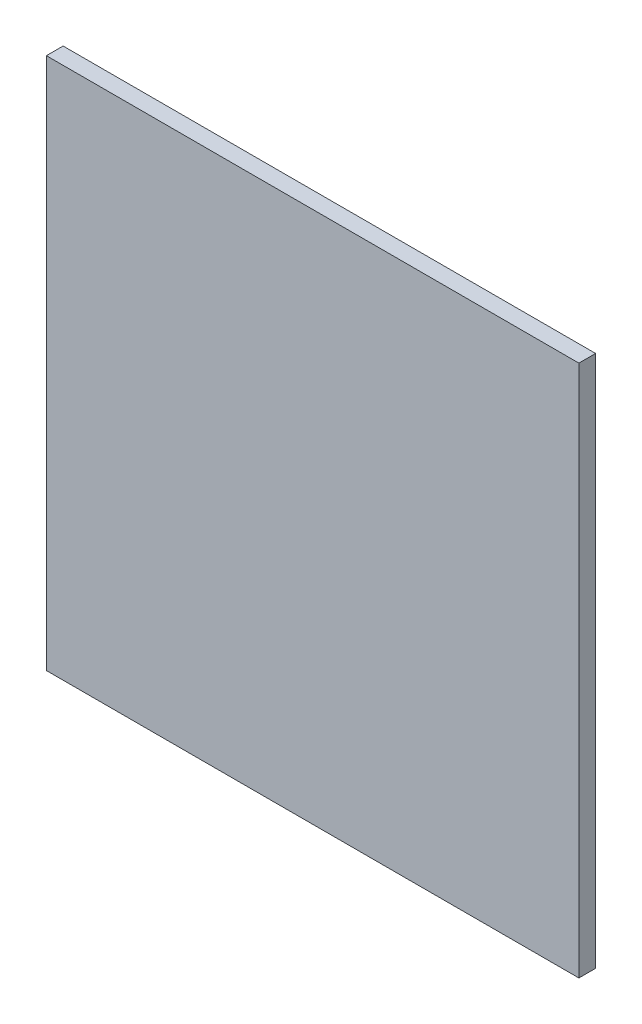
from build123d import *

# Parameters (mm, degrees)
SKETCH_1_W      = 35
SKETCH_1_H      = 35
EXTRUDE_1_DEPTH = 1.1


with BuildPart() as part:
    # 草图1 → 凸台-拉伸1 (new body)
    with BuildSketch(Plane.XY):
        Rectangle(SKETCH_1_W, SKETCH_1_H)
    extrude(amount=EXTRUDE_1_DEPTH)


solid = part.part
